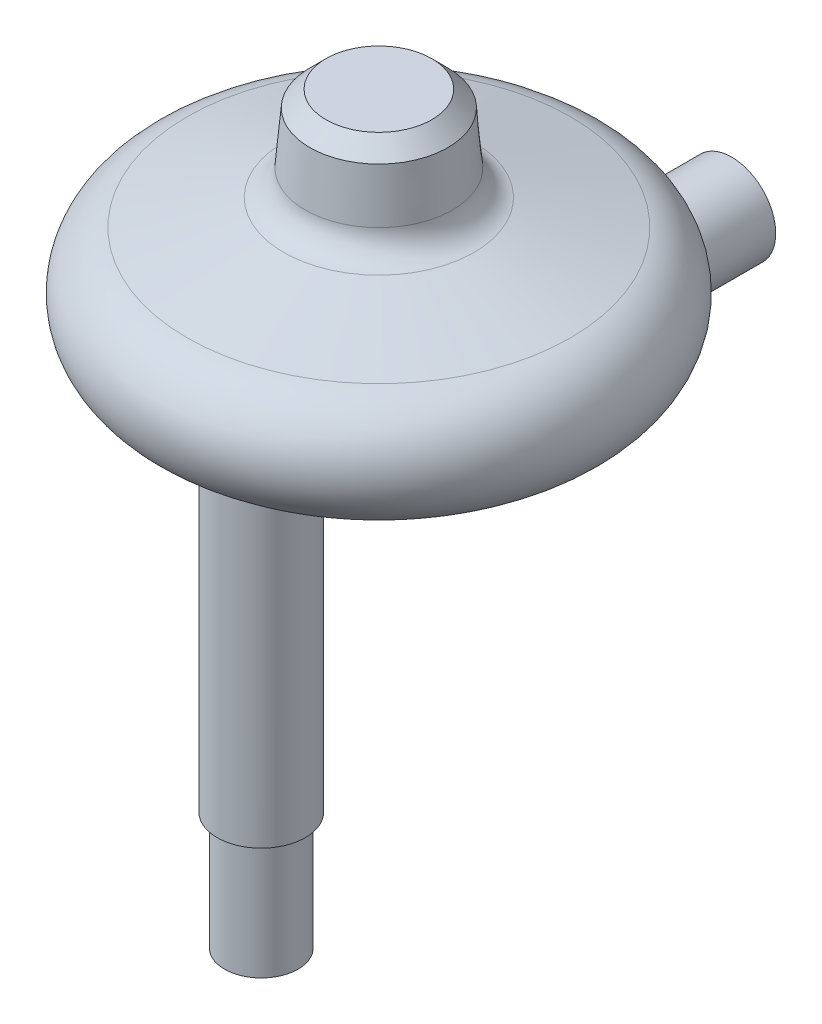
from build123d import *

# Parameters (mm, degrees)
SKETCH2_R           = 9.525
BOSS_EXTRUDE1_DEPTH = 25.4
BOSS_EXTRUDE1_TAPER = 5
FILLET1_R           = 3.175
SKETCH3_R           = 4.7625
BOSS_EXTRUDE2_DEPTH = 35.875
FILLET2_R           = 3.175
BOSS_EXTRUDE3_DEPTH = 19.05
FILLET4_R           = 1.5875
FILLET8_R           = 1.5875
CHAMFER1_SIZE2      = 1.5875
CHAMFER1_SIZE       = 1.746349802
SKETCH5_R           = 4.7625
BOSS_EXTRUDE4_DEPTH = 12.7
SKETCH6_R           = 3.96875
BOSS_EXTRUDE5_DEPTH = 12.7


with BuildPart() as part:
    # Sketch1 → Base-Revolve (revolve)
    with BuildSketch(Plane.XY):
        with BuildLine():
            Line((0, 0), (19.05, 0))
            ThreePointArc((19.05, 0), (25.34567487, 5.521158679), (20.693500936, 12.483628997))
            Line((20.693500936, 12.483628997), (0, 18.028435861))
            Line((0, 18.028435861), (0, 0))
        make_face()
    revolve(axis=Axis((0, 0, 0), (0, 1, 0)))

    # Sketch2 → Boss-Extrude1 (add)
    with BuildSketch(Plane.XZ):
        Circle(SKETCH2_R)
    extrude(amount=-BOSS_EXTRUDE1_DEPTH, taper=BOSS_EXTRUDE1_TAPER)

    # Fillet1
    fillet1_edges = [part.edges().sort_by_distance(p)[0] for p in [
        (-8.138503239, 15.847730491, 0),
    ]]
    fillet(fillet1_edges, radius=FILLET1_R)

    # Sketch3 → Boss-Extrude2 (add)
    with BuildSketch(Plane.XZ):
        with Locations((0, 12.7)):
            Circle(SKETCH3_R)
    extrude(amount=BOSS_EXTRUDE2_DEPTH)

    # Fillet2
    fillet2_edges = [part.edges().sort_by_distance(p)[0] for p in [
        (-4.7625, 0, 12.7),
    ]]
    fillet(fillet2_edges, radius=FILLET2_R)

    # Sketch4 → Boss-Extrude3 (add)
    with BuildSketch(Plane.XY.offset(-6.35)):
        with BuildLine():
            Line((-4.7625, 1.5875), (4.7625, 1.5875))
            Line((4.7625, 1.5875), (4.7625, -4.7625))
            ThreePointArc((4.7625, -4.7625), (0, -9.525), (-4.7625, -4.7625))
            Line((-4.7625, -4.7625), (-4.7625, 1.5875))
        make_face()
    extrude(amount=-BOSS_EXTRUDE3_DEPTH)

    # Fillet4
    fillet4_edges = [part.edges().sort_by_distance(p)[0] for p in [
        (4.7625, -2.38125, -6.35),
        (-4.7625, -2.38125, -6.35),
        (0, -9.525, -6.35),
    ]]
    fillet(fillet4_edges, radius=FILLET4_R)

    # Fillet8
    fillet8_edges = [part.edges().sort_by_distance(p)[0] for p in [
        (-20.693500936, 12.483628997, 0),
        (-20.693500936, 12.483628997, 0),
        (4.7625, 0, -13.191291593),
        (0, 0, -6.35),
        (-4.7625, 0, -13.191291593),
        (4.297532015, 0, -6.814967985),
        (-4.297532015, 0, -6.814967985),
    ]]
    fillet(fillet8_edges, radius=FILLET8_R)

    # Chamfer1
    chamfer1_edges = [part.edges().sort_by_distance(p)[0] for p in [
        (-7.302787946, 25.4, 0),
    ]]
    chamfer(chamfer1_edges, length=CHAMFER1_SIZE, length2=CHAMFER1_SIZE2)

    # Sketch5 → Boss-Extrude4 (add)
    with BuildSketch(Plane(origin=(0, 0, -25.4), x_dir=(-1, 0, 0), z_dir=(0, 0, -1))):
        with Locations((0, -4.7625)):
            Circle(SKETCH5_R)
    extrude(amount=BOSS_EXTRUDE4_DEPTH)

    # Sketch6 → Boss-Extrude5 (add)
    with BuildSketch(Plane.XZ.offset(35.875)):
        with Locations((0, 12.7)):
            Circle(SKETCH6_R)
    extrude(amount=BOSS_EXTRUDE5_DEPTH)


solid = part.part
